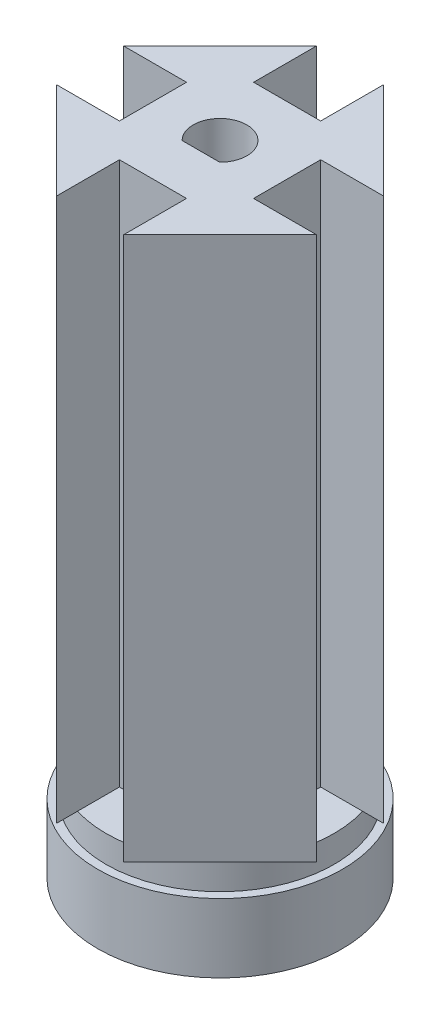
from build123d import *

# Parameters (mm, degrees)
BOSS_EXTRUDE8_DEPTH           = 0.255
BOSS_EXTRUDE8_DEPTH_BACK      = 10
SKETCH13_R                    = 18.25
SKETCH13_R_2                  = 17
SKETCH14_R                    = 17
SKETCH14_R_2                  = 4
BOSS_EXTRUDE17_DEPTH          = 5
CONNECTOR_CYLINDER_DEPTH      = 80
CONNECTOR_CYLINDER_DEPTH_BACK = 1
SKETCH21_R                    = 20
SKETCH23_R                    = 4
CUT_EXTRUDE4_DEPTH            = 96.3
CONNECTOR_CYLINDER_CUT_DEPTH  = 81
CUT_EXTRUDE5_DEPTH            = 81
KEY_CUT_DEPTH                 = 85


with BuildPart() as part:
    # Sketch13 → Boss-Extrude8 (new, two sides: drawn at the far end of the back side and taken through both)
    with BuildSketch(Plane(origin=(0, 0, 0), x_dir=(1, 0, 0), z_dir=(0, 1, 0)).offset(-BOSS_EXTRUDE8_DEPTH_BACK)):
        with Locations(Location((0, 0, 0), (0, 0, 270))):
            Circle(SKETCH13_R)
        with Locations(Location((0, 0, 0), (0, 0, 270))):
            Circle(SKETCH13_R_2, mode=Mode.SUBTRACT)
    extrude(amount=BOSS_EXTRUDE8_DEPTH + BOSS_EXTRUDE8_DEPTH_BACK)


with BuildPart() as body_2:
    # Sketch14 → Boss-Extrude17 (new body)
    # profile 1 of 2: a face of its own
    with BuildSketch(Plane(origin=(0, 0.255, 0), x_dir=(1, 0, 0), z_dir=(0, 1, 0))):
        with Locations(Location((0, 0, 0), (0, 0, 270))):
            Circle(SKETCH14_R)
        Circle(SKETCH14_R_2, mode=Mode.SUBTRACT)
    # profile 2 of 2: a face of its own
    with BuildSketch(Plane(origin=(0, 0.255, 0), x_dir=(1, 0, 0), z_dir=(0, 1, 0))):
        with BuildLine():
            ThreePointArc((2.066246597, 3.425), (0, 4), (-2.066246597, 3.425))
            Line((-2.066246597, 3.425), (0, 3.425))
            Line((0, 3.425), (2.066246597, 3.425))
        make_face()
    extrude(amount=BOSS_EXTRUDE17_DEPTH)

    # Sketch21 → Connector Cylinder (add, two sides: drawn at the far end of the back side and taken through both)
    with BuildSketch(Plane(origin=(0, 5.255, 0), x_dir=(1, 0, 0), z_dir=(0, 1, 0)).offset(-CONNECTOR_CYLINDER_DEPTH_BACK)):
        with Locations(Location((0, 0, 0), (0, 0, 270))):
            Circle(SKETCH21_R)
    extrude(amount=CONNECTOR_CYLINDER_DEPTH + CONNECTOR_CYLINDER_DEPTH_BACK)

    # Sketch23 → Cut-Extrude4 (cut)
    with BuildSketch(Plane(origin=(0, 85.255, 0), x_dir=(1, 0, 0), z_dir=(0, 1, 0))):
        with Locations(Location((0, 0, 0), (0, 0, 270))):
            Circle(SKETCH23_R)
    extrude(amount=-CUT_EXTRUDE4_DEPTH, mode=Mode.SUBTRACT)

    # Sketch22 → Connector Cylinder Cut (cut)
    with BuildSketch(Plane(origin=(0, 85.255, 0), x_dir=(1, 0, 0), z_dir=(0, 1, 0))):
        with BuildLine():
            ThreePointArc((-5, -19.364916731), (0, -20), (5, -19.364916731))
            Line((5, -19.364916731), (5, -10))
            Line((5, -10), (-5, -10))
            Line((-5, -10), (-5, -19.364916731))
        make_face()
        with BuildLine():
            ThreePointArc((-19.364916731, 5), (-20, 0), (-19.364916731, -5))
            Line((-19.364916731, -5), (-10, -5))
            Line((-10, -5), (-10, 5))
            Line((-10, 5), (-19.364916731, 5))
        make_face()
        with BuildLine():
            Line((5, 10), (5, 19.364916731))
            ThreePointArc((5, 19.364916731), (0, 20), (-5, 19.364916731))
            Line((-5, 19.364916731), (-5, 10))
            Line((-5, 10), (5, 10))
        make_face()
        with BuildLine():
            Line((9.999996731, 5), (9.999996731, -5))
            Line((9.999996731, -5), (19.364916731, -5))
            ThreePointArc((19.364916731, -5), (19.840593925, -2.52008585), (20, 0))
            ThreePointArc((20, 0), (19.840593925, 2.52008585), (19.364916731, 5))
            Line((19.364916731, 5), (9.999996731, 5))
        make_face()
    extrude(amount=-CONNECTOR_CYLINDER_CUT_DEPTH, mode=Mode.SUBTRACT)

    # Sketch24 → Cut-Extrude5 (cut)
    with BuildSketch(Plane(origin=(0, 85.255, 0), x_dir=(1, 0, 0), z_dir=(0, 1, 0))):
        with BuildLine():
            Line((-5, 19.364916731), (-19.364916731, 5))
            ThreePointArc((-19.364916731, 5), (-14.142135624, 14.142135624), (-5, 19.364916731))
        make_face()
        with BuildLine():
            Line((5, 19.364916731), (19.364916731, 5))
            ThreePointArc((19.364916731, 5), (14.142135624, 14.142135624), (5, 19.364916731))
        make_face()
        with BuildLine():
            Line((19.364916731, -5), (5, -19.364916731))
            ThreePointArc((5, -19.364916731), (14.142135624, -14.142135624), (19.364916731, -5))
        make_face()
        with BuildLine():
            Line((-5, -19.364916731), (-19.364916731, -5))
            ThreePointArc((-19.364916731, -5), (-14.142135624, -14.142135624), (-5, -19.364916731))
        make_face()
    extrude(amount=-CUT_EXTRUDE5_DEPTH, mode=Mode.SUBTRACT)

    # Sketch25 → Key Cut (add)
    with BuildSketch(Plane.XZ.offset(-0.255)):
        with BuildLine():
            ThreePointArc((2.80668844, 2.85), (0, 4), (-2.80668844, 2.85))
            Line((-2.80668844, 2.85), (2.80668844, 2.85))
        make_face()
    extrude(amount=-KEY_CUT_DEPTH)


solid = Compound([part.part, body_2.part])
